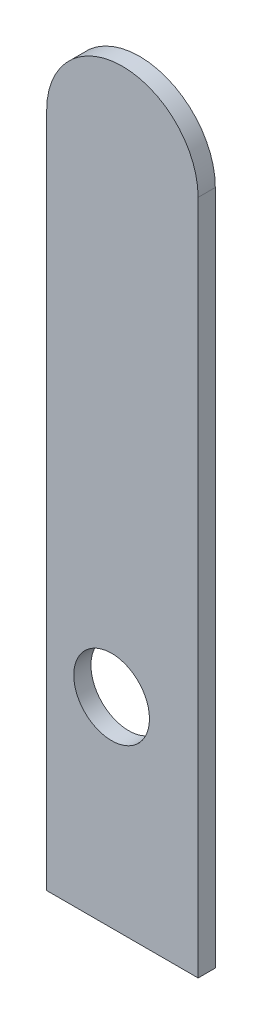
from build123d import *

# Parameters (mm, degrees)
MODEL_R             = 3.5
BOSS_EXTRUDE1_DEPTH = 1.5875


with BuildPart() as part:
    # Model → Boss-Extrude1 (new body)
    with BuildSketch(Plane.XY):
        with BuildLine():
            Line((0, 0), (0, 62.5))
            ThreePointArc((0, 62.5), (7, 69.5), (14, 62.5))
            Line((14, 62.5), (14, 0))
            Line((14, 0), (0, 0))
        make_face()
        with Locations((6, 18.5)):
            Circle(MODEL_R, mode=Mode.SUBTRACT)
    extrude(amount=BOSS_EXTRUDE1_DEPTH)


solid = part.part
